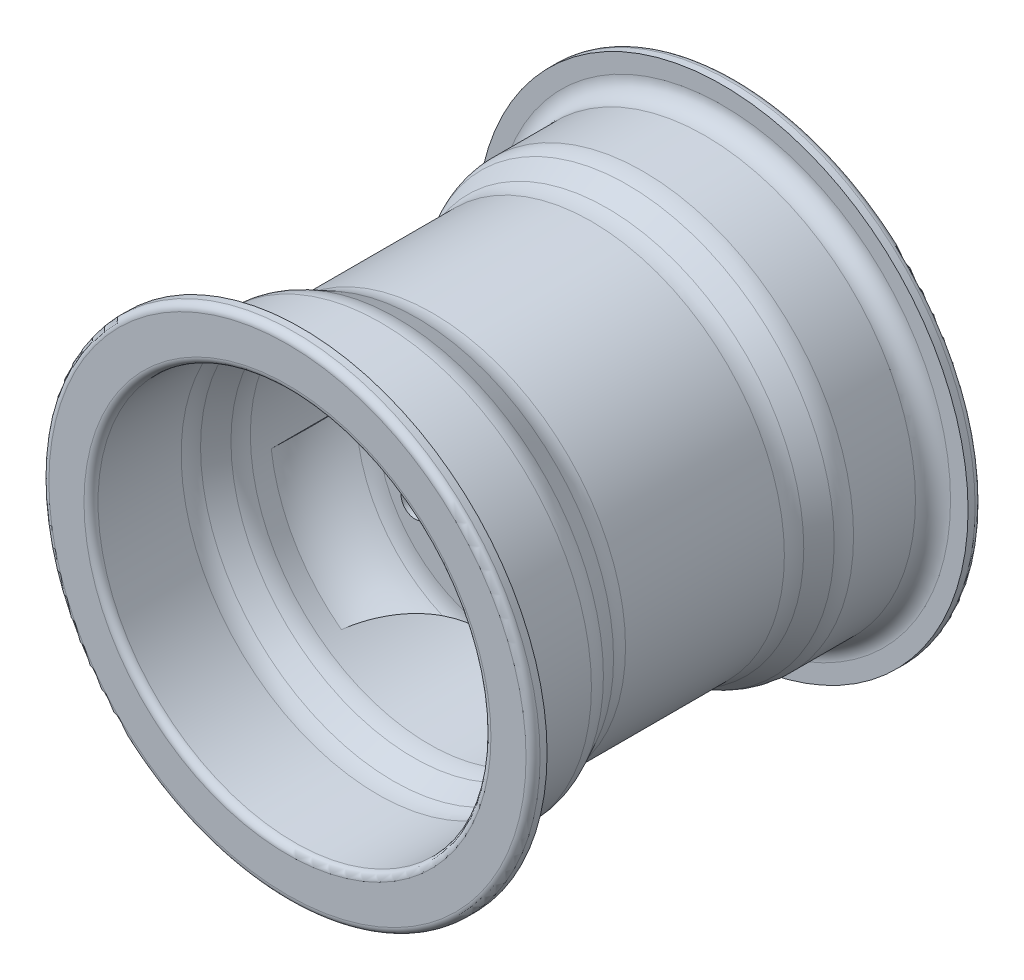
from build123d import *

# Parameters (mm, degrees)
SKETCH2_R               = 4
CUT_EXTRUDE1_DEPTH      = 65
CUT_EXTRUDE1_DEPTH_BACK = 65


with BuildPart() as part:
    # Sketch1 → Revolve1 (revolve)
    with BuildSketch(Plane(origin=(0, 0, 0), x_dir=(0, 0, -1), z_dir=(1, 0, 0))):
        with BuildLine():
            Line((-60, 70), (-60, 65))
            ThreePointArc((-60, 65), (-58.535533906, 61.464466094), (-55, 60))
            Line((-55, 60), (-37.360679775, 60))
            ThreePointArc((-37.360679775, 60), (-35.06315057, 59.732489895), (-32.88854382, 58.94427191))
            Line((-32.88854382, 58.94427191), (-27.11145618, 56.05572809))
            ThreePointArc((-27.11145618, 56.05572809), (-24.93684943, 55.267510105), (-22.639320225, 55))
            Line((-22.639320225, 55), (22.639320225, 55))
            ThreePointArc((22.639320225, 55), (24.93684943, 55.267510105), (27.11145618, 56.05572809))
            Line((27.11145618, 56.05572809), (32.88854382, 58.94427191))
            ThreePointArc((32.88854382, 58.94427191), (35.06315057, 59.732489895), (37.360679775, 60))
            Line((37.360679775, 60), (55, 60))
            ThreePointArc((55, 60), (58.535533906, 61.464466094), (60, 65))
            Line((60, 65), (60, 70))
            Line((60, 70), (62, 70))
            ThreePointArc((62, 70), (63.414213562, 69.414213562), (64, 68))
            Line((64, 68), (64, 58))
            ThreePointArc((64, 58), (63.414213562, 56.585786438), (62, 56))
            Line((62, 56), (38.304951685, 56))
            ThreePointArc((38.304951685, 56), (36.00742248, 55.732489895), (33.83281573, 54.94427191))
            Line((33.83281573, 54.94427191), (28.05572809, 52.05572809))
            ThreePointArc((28.05572809, 52.05572809), (25.88112134, 51.267510105), (23.583592135, 51))
            Line((23.583592135, 51), (18, 51))
            ThreePointArc((18, 51), (9.623718705, 47.491216353), (3.66261042, 40.640023829))
            ThreePointArc((3.66261042, 40.640023829), (2.795003972, 38.37124916), (2.5, 35.960221972))
            Line((2.5, 35.960221972), (2.5, 20))
            Line((2.5, 20), (-2.5, 20))
            Line((-2.5, 20), (-2.5, 35.960221972))
            ThreePointArc((-2.5, 35.960221972), (-2.795003972, 38.37124916), (-3.66261042, 40.640023829))
            ThreePointArc((-3.66261042, 40.640023829), (-9.623718705, 47.491216353), (-18, 51))
            Line((-18, 51), (-23.583592135, 51))
            ThreePointArc((-23.583592135, 51), (-25.88112134, 51.267510105), (-28.05572809, 52.05572809))
            Line((-28.05572809, 52.05572809), (-33.83281573, 54.94427191))
            ThreePointArc((-33.83281573, 54.94427191), (-36.00742248, 55.732489895), (-38.304951685, 56))
            Line((-38.304951685, 56), (-62, 56))
            ThreePointArc((-62, 56), (-63.414213562, 56.585786438), (-64, 58))
            Line((-64, 58), (-64, 68))
            ThreePointArc((-64, 68), (-63.414213562, 69.414213562), (-62, 70))
            Line((-62, 70), (-60, 70))
        make_face()
    revolve(axis=Axis((0, 0, 51.361173414), (0, 0, -1)))

    # Sketch2 → Cut-Extrude1 (cut, two sides)
    with BuildSketch(Plane.XY) as cut_extrude1_sk:
        with Locations((0, 29)):
            Circle(SKETCH2_R)
        with Locations((25.11473671, -14.5)):
            Circle(SKETCH2_R)
        with Locations((-25.11473671, -14.5)):
            Circle(SKETCH2_R)
        with BuildLine():
            ThreePointArc((-20, 46.914816423), (-44.167295593, 25.5), (-50.629422836, -6.136900136))
            ThreePointArc((-50.629422836, -6.136900136), (-31.150018848, 17.984471767), (-20, 46.914816423))
        make_face()
        with BuildLine():
            ThreePointArc((50.629422836, -6.136900136), (31.150018848, 17.984471767), (20, 46.914816423))
            ThreePointArc((20, 46.914816423), (44.167295593, 25.5), (50.629422836, -6.136900136))
        make_face()
        with BuildLine():
            ThreePointArc((-30.629422836, -40.777916287), (0, -35.968943535), (30.629422836, -40.777916287))
            ThreePointArc((30.629422836, -40.777916287), (0, -51), (-30.629422836, -40.777916287))
        make_face()
    extrude(amount=CUT_EXTRUDE1_DEPTH, mode=Mode.SUBTRACT)
    extrude(cut_extrude1_sk.sketch, amount=-CUT_EXTRUDE1_DEPTH_BACK, mode=Mode.SUBTRACT)


solid = part.part
